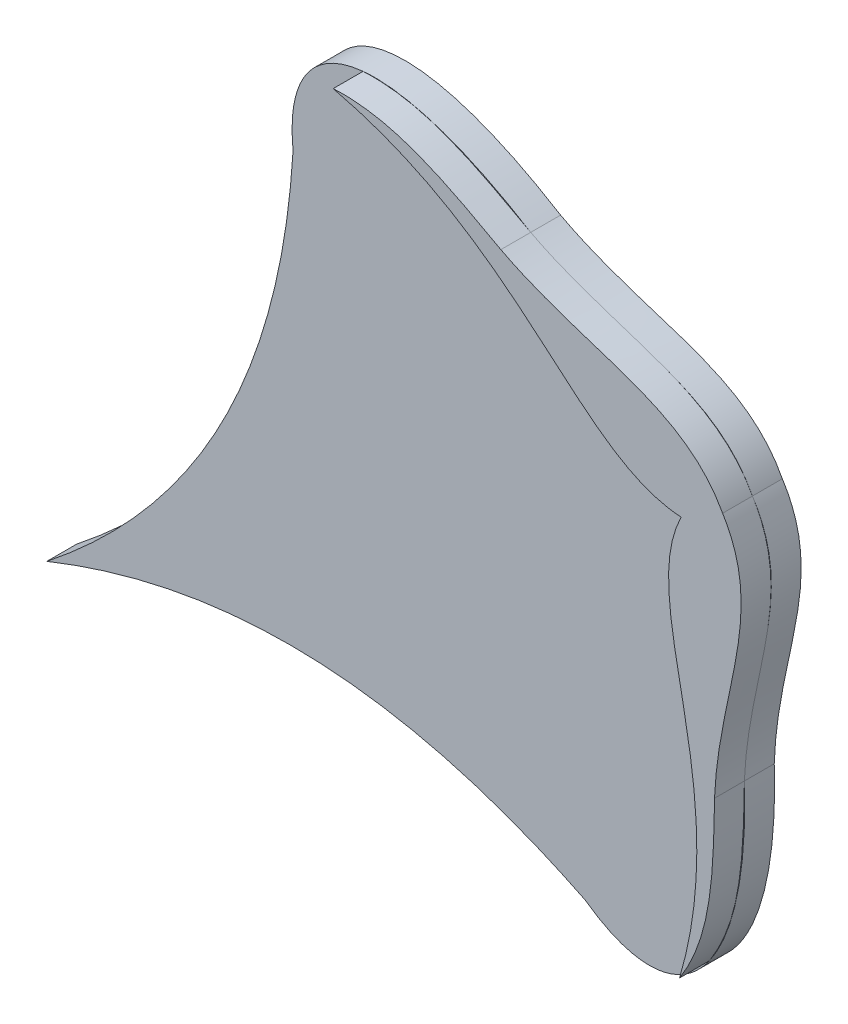
from build123d import *

# Parameters (mm, degrees)
BOSS_EXTRUDE1_DEPTH = 10
BOSS_EXTRUDE2_DEPTH = 10


with BuildPart() as part:
    # Sketch1 → Boss-Extrude1 (new body)
    with BuildSketch(Plane.XY):
        with BuildLine():
            add(Edge.make_bspline(
                [(1252.955787897, 934.562229178), (1240.055303758, 959.428610854), (1208.365187, 958.139461479), (1178.69199211, 973.903346264)],
                knots=[0, 0, 0, 0, 1, 1, 1, 1], degree=3))
            add(Edge.make_bspline(
                [(1178.69199211, 973.903346264), (1128.978750358, 1004.598770701), (1095.043421859, 996.66829496), (1099.111384517, 957.8661896)],
                knots=[0, 0, 0, 0, 1, 1, 1, 1], degree=3))
            add(Edge.make_bspline(
                [(1099.111384517, 957.8661896), (1095.490174888, 897.857572891), (1073.118013743, 842.106722885), (1016.645934102, 797.470508127)],
                knots=[0, 0, 0, 0, 1, 1, 1, 1], degree=3))
            add(Edge.make_bspline(
                [(1196.820465005, 789.441587826), (1142.929228565, 816.08519632), (1083.426542959, 824.337546066), (1016.645934102, 797.470508127)],
                knots=[0, 0, 0, 0, 1, 1, 1, 1], degree=3))
            add(Edge.make_bspline(
                [(1250.244767726, 850.565293354), (1252.214837872, 792.172363041), (1228.485472959, 766.649506487), (1196.820465005, 789.441587826)],
                knots=[0, 0, 0, 0, 1, 1, 1, 1], degree=3))
            add(Edge.make_bspline(
                [(1252.955787897, 934.562229178), (1268.138830869, 911.020040775), (1251.289312028, 884.149627286), (1250.244767726, 850.565293354)],
                knots=[0, 0, 0, 0, 1, 1, 1, 1], degree=3))
        make_face()
    extrude(amount=BOSS_EXTRUDE1_DEPTH)

    # Sketch2 → Boss-Extrude2 (add)
    with BuildSketch(Plane.XY.offset(10)):
        with BuildLine():
            add(Edge.make_bspline(
                [(1239.046859662, 926.493166974), (1223.649185402, 895.028097144), (1257.099026818, 855.762298455), (1238.540537409, 792.579129425)],
                knots=[0, 0, 0, 0, 1, 1, 1, 1], degree=3))
            add(Edge.make_bspline(
                [(1238.540537409, 792.579129425), (1249.542860844, 809.642956465), (1249.853618496, 828.950841044), (1250.244767726, 850.565293354)],
                knots=[0, 0, 0, 0, 1, 1, 1, 1], degree=3))
            add(Edge.make_bspline(
                [(1252.955787897, 934.562229178), (1267.789500837, 910.798382917), (1251.54864504, 883.502823378), (1250.244767726, 850.565293354)],
                knots=[0, 0, 0, 0, 1, 1, 1, 1], degree=3))
            add(Edge.make_bspline(
                [(1252.955787897, 934.562229178), (1239.689480504, 959.235382946), (1207.932422032, 958.685651363), (1178.69199211, 973.903346264)],
                knots=[0, 0, 0, 0, 1, 1, 1, 1], degree=3))
            add(Edge.make_bspline(
                [(1122.544189663, 992.526141298), (1142.818724947, 993.607128458), (1159.734235476, 984.292812554), (1178.69199211, 973.903346264)],
                knots=[0, 0, 0, 0, 1, 1, 1, 1], degree=3))
            add(Edge.make_bspline(
                [(1239.046859662, 926.493166974), (1204.088771841, 928.745074604), (1186.60586484, 977.273857818), (1122.544189663, 992.526141298)],
                knots=[0, 0, 0, 0, 1, 1, 1, 1], degree=3))
        make_face()
    extrude(amount=BOSS_EXTRUDE2_DEPTH)


solid = part.part
